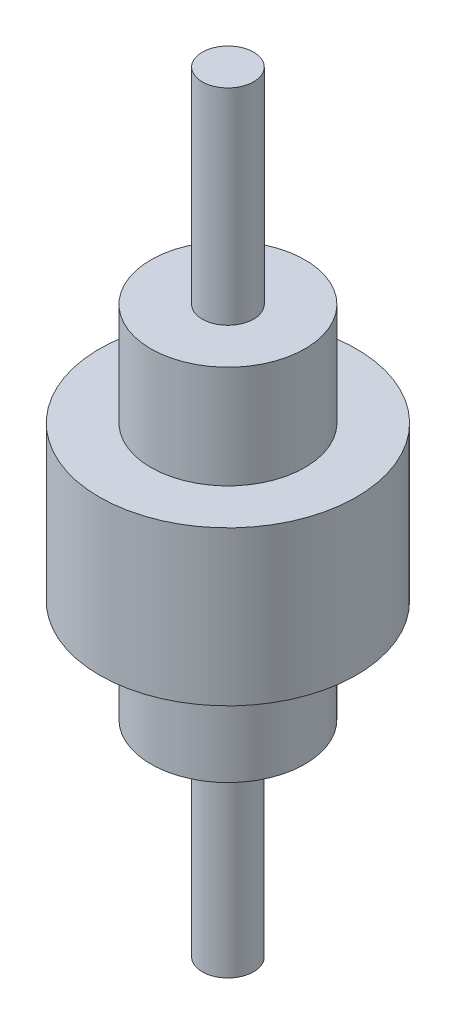
from build123d import *

# Parameters (mm, degrees)
SKETCH2_R           = 50
BOSS_EXTRUDE1_DEPTH = 60
SKETCH3_R           = 30
BOSS_EXTRUDE2_DEPTH = 40
SKETCH4_R           = 10
BOSS_EXTRUDE3_DEPTH = 80
SKETCH5_R           = 30
BOSS_EXTRUDE4_DEPTH = 40
SKETCH6_R           = 10
BOSS_EXTRUDE5_DEPTH = 80


with BuildPart() as part:
    # Sketch2 → Boss-Extrude1 (new body)
    with BuildSketch(Plane(origin=(0, 0, 0), x_dir=(1, 0, 0), z_dir=(0, 1, 0))):
        Circle(SKETCH2_R)
    extrude(amount=BOSS_EXTRUDE1_DEPTH)

    # Sketch3 → Boss-Extrude2 (add)
    with BuildSketch(Plane(origin=(0, 60, 0), x_dir=(1, 0, 0), z_dir=(0, 1, 0))):
        Circle(SKETCH3_R)
    extrude(amount=BOSS_EXTRUDE2_DEPTH)

    # Sketch4 → Boss-Extrude3 (add)
    with BuildSketch(Plane(origin=(0, 100, 0), x_dir=(1, 0, 0), z_dir=(0, 1, 0))):
        Circle(SKETCH4_R)
    extrude(amount=BOSS_EXTRUDE3_DEPTH)

    # Sketch5 → Boss-Extrude4 (add)
    with BuildSketch(Plane.XZ):
        Circle(SKETCH5_R)
    extrude(amount=BOSS_EXTRUDE4_DEPTH)

    # Sketch6 → Boss-Extrude5 (add)
    with BuildSketch(Plane.XZ.offset(40)):
        Circle(SKETCH6_R)
    extrude(amount=BOSS_EXTRUDE5_DEPTH)


solid = part.part
